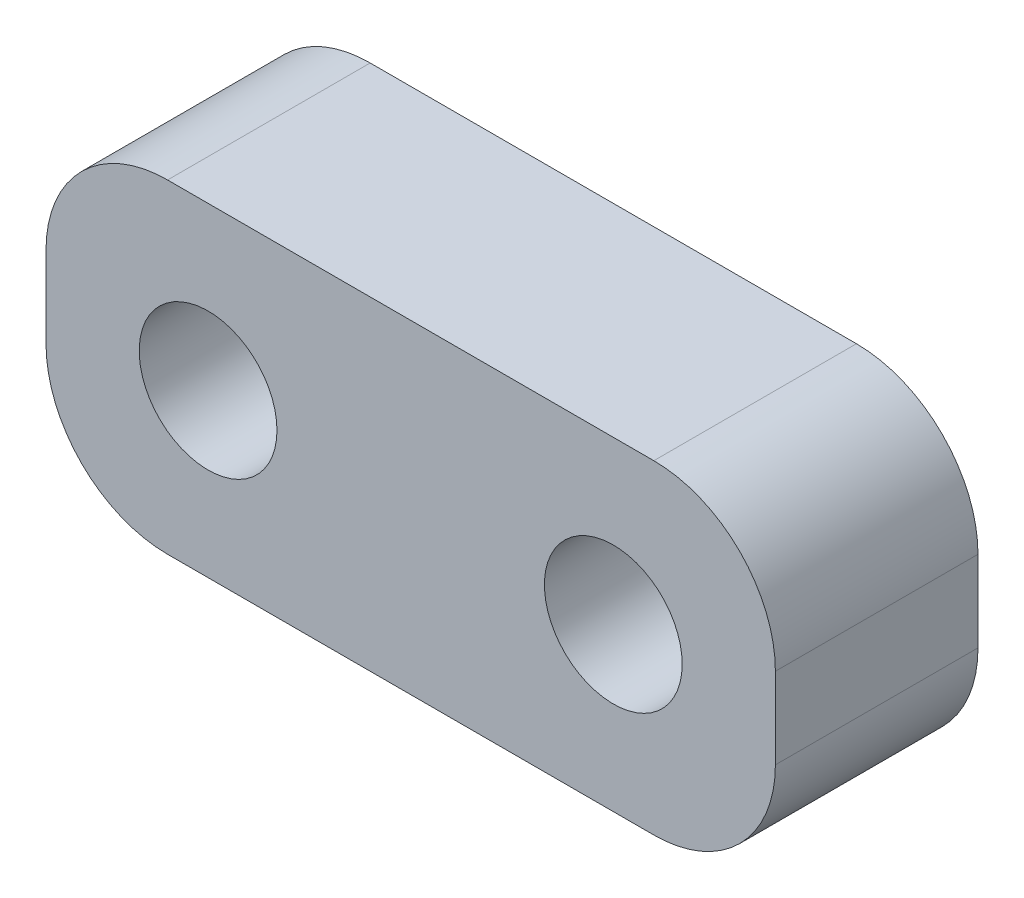
from build123d import *

# Parameters (mm, degrees)
SKETCH1_W            = 18
SKETCH1_H            = 8
BOSS_EXTRUDE1_DEPTH  = 2.5
M3_CLEARANCE_HOLE1_D = 3.4
FILLET1_R            = 3


with BuildPart() as part:
    # Sketch1 → Boss-Extrude1 (new, symmetric)
    with BuildSketch(Plane.XY):
        Rectangle(SKETCH1_W, SKETCH1_H)
    extrude(amount=BOSS_EXTRUDE1_DEPTH, both=True)

    # M3 Clearance Hole1 (through all)
    with Locations(Plane.XY.offset(2.5)):
        with Locations((-5, 0), (5, 0)):
            Hole(M3_CLEARANCE_HOLE1_D / 2)

    # Fillet1
    fillet1_edges = [part.edges().sort_by_distance(p)[0] for p in [
        (-9, 4, 0),
        (-9, -4, 0),
        (9, -4, 0),
        (9, 4, 0),
    ]]
    fillet(fillet1_edges, radius=FILLET1_R)


solid = part.part
